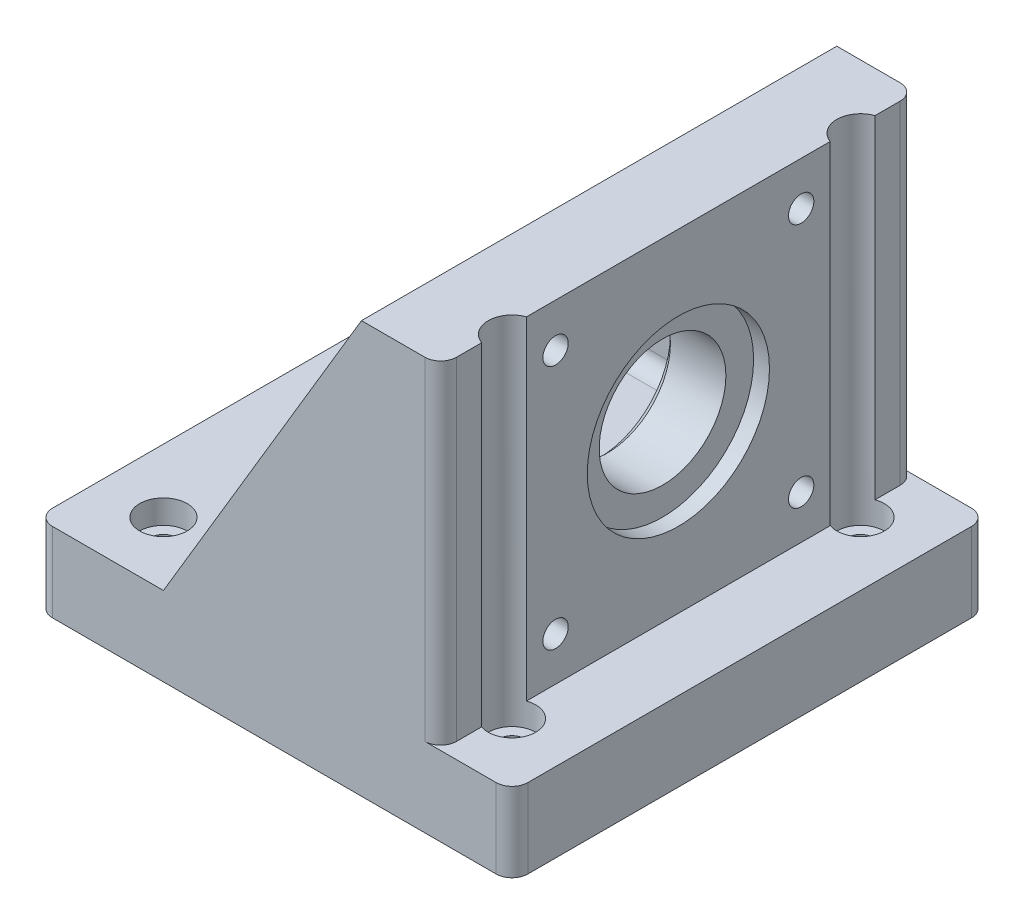
from build123d import *

# Parameters (mm, degrees)
SKETCH1_W               = 60
SKETCH1_H               = 60
SKETCH1_R               = 1.6
SKETCH1_W_2             = 12
SKETCH1_H_2             = 22
BOSS_EXTRUDE1_DEPTH     = 10
BOSS_EXTRUDE2_DEPTH     = 42
SKETCH3_R               = 11.5
CUT_EXTRUDE1_DEPTH      = 2
SKETCH4_R               = 8
CUT_EXTRUDE2_DEPTH      = 8
SKETCH5_R               = 1.6
CUT_EXTRUDE3_DEPTH      = 10
SKETCH6_R               = 3
CUT_EXTRUDE4_DEPTH      = 3
SKETCH7_R               = 3
CUT_EXTRUDE5_DEPTH      = 43
CUT_EXTRUDE6_DEPTH      = 31
CUT_EXTRUDE6_DEPTH_BACK = 31
FILLET1_R               = 2
FILLET2_R               = 2
CHAMFER1_SIZE           = 1


with BuildPart() as part:
    # Sketch1 → Boss-Extrude1 (new body)
    with BuildSketch(Plane(origin=(0, 0, 0), x_dir=(1, 0, 0), z_dir=(0, 1, 0))):
        Rectangle(SKETCH1_W, SKETCH1_H)
        with Locations((-22, 22)):
            Circle(SKETCH1_R, mode=Mode.SUBTRACT)
        with Locations((22, 22)):
            Circle(SKETCH1_R, mode=Mode.SUBTRACT)
        with Locations((-22, -22)):
            Circle(SKETCH1_R, mode=Mode.SUBTRACT)
        with Locations((22, -22)):
            Circle(SKETCH1_R, mode=Mode.SUBTRACT)
        Rectangle(SKETCH1_W_2, SKETCH1_H_2, mode=Mode.SUBTRACT)
    extrude(amount=BOSS_EXTRUDE1_DEPTH)

    # Sketch2 → Boss-Extrude2 (add)
    with BuildSketch(Plane(origin=(0, 10, 0), x_dir=(1, 0, 0), z_dir=(0, 1, 0))):
        Polygon((11, 30), (21, 30), (21, -30), (11, -30), (-14, -30), (-14, -25), (11, -25), (11, 25), (-14, 25), (-14, 30), align=None)
    extrude(amount=BOSS_EXTRUDE2_DEPTH)

    # Sketch3 → Cut-Extrude1 (cut)
    with BuildSketch(Plane(origin=(21, 0, 0), x_dir=(0, 0, -1), z_dir=(1, 0, 0))):
        with Locations((0, 31)):
            Circle(SKETCH3_R)
    extrude(amount=-CUT_EXTRUDE1_DEPTH, mode=Mode.SUBTRACT)

    # Sketch4 → Cut-Extrude2 (cut)
    with BuildSketch(Plane(origin=(19, 0, 0), x_dir=(0, 0, -1), z_dir=(1, 0, 0))):
        with Locations((0, 31)):
            Circle(SKETCH4_R)
    extrude(amount=-CUT_EXTRUDE2_DEPTH, mode=Mode.SUBTRACT)

    # Sketch5 → Cut-Extrude3 (cut)
    with BuildSketch(Plane(origin=(21, 0, 0), x_dir=(0, 0, -1), z_dir=(1, 0, 0))):
        with Locations((-15.5, 46.5)):
            Circle(SKETCH5_R)
        with Locations((15.5, 46.5)):
            Circle(SKETCH5_R)
        with Locations((15.5, 15.5)):
            Circle(SKETCH5_R)
        with Locations((-15.5, 15.5)):
            Circle(SKETCH5_R)
    extrude(amount=-CUT_EXTRUDE3_DEPTH, mode=Mode.SUBTRACT)

    # Sketch6 → Cut-Extrude4 (cut)
    with BuildSketch(Plane(origin=(0, 10, 0), x_dir=(1, 0, 0), z_dir=(0, 1, 0))):
        with Locations((-22, 22)):
            Circle(SKETCH6_R)
        with Locations((22, 22)):
            Circle(SKETCH6_R)
        with Locations((22, -22)):
            Circle(SKETCH6_R)
        with Locations((-22, -22)):
            Circle(SKETCH6_R)
    extrude(amount=-CUT_EXTRUDE4_DEPTH, mode=Mode.SUBTRACT)

    # Sketch7 → Cut-Extrude5 (cut, through all)
    with BuildSketch(Plane(origin=(0, 10, 0), x_dir=(1, 0, 0), z_dir=(0, 1, 0))):
        with Locations((22, 22)):
            Circle(SKETCH7_R)
        with Locations((22, -22)):
            Circle(SKETCH7_R)
    extrude(amount=CUT_EXTRUDE5_DEPTH, mode=Mode.SUBTRACT)

    # Sketch10 → Cut-Extrude6 (cut, two sides)
    with BuildSketch(Plane.XY) as cut_extrude6_sk:
        Polygon((11, 52), (-14, 10), (-19.679988527, 22.361973952), (-19.679988527, 54.584490378), (11, 54.584490378), align=None)
    extrude(amount=CUT_EXTRUDE6_DEPTH, mode=Mode.SUBTRACT)
    extrude(cut_extrude6_sk.sketch, amount=-CUT_EXTRUDE6_DEPTH_BACK, mode=Mode.SUBTRACT)

    # Fillet1
    fillet1_edges = [part.edges().sort_by_distance(p)[0] for p in [
        (21, 31, 30),
        (21, 31, -30),
        (-1.5, 10, -25),
        (11, 10, 0),
        (11, 31, -25),
        (-1.5, 10, 25),
        (11, 31, 25),
    ]]
    fillet(fillet1_edges, radius=FILLET1_R)

    # Fillet2
    fillet2_edges = [part.edges().sort_by_distance(p)[0] for p in [
        (30, 5, 30),
        (-30, 5, 30),
        (-30, 5, -30),
        (30, 5, -30),
    ]]
    fillet(fillet2_edges, radius=FILLET2_R)

    # Chamfer1
    chamfer1_edges = [part.edges().sort_by_distance(p)[0] for p in [
        (11, 31, 8),
    ]]
    chamfer(chamfer1_edges, length=CHAMFER1_SIZE)


solid = part.part
